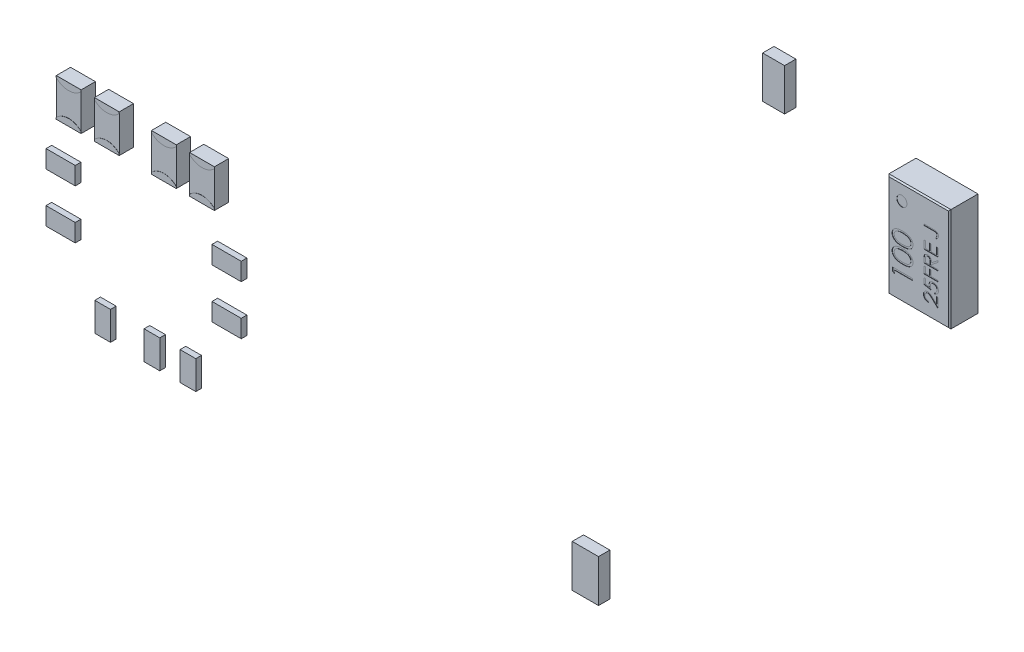
from build123d import *

# Parameters (mm, degrees)
SZKIC1_W                      = 4.373721056
SZKIC1_H                      = 7.300749762
DODANIE_WYCI_GNI_CIE1_DEPTH   = 2
SFAZOWANIE1_SIZE              = 0.09
SZKIC2_R                      = 0.357953931
WYTNIJ_WYCI_GNI_CIE1_DEPTH    = 0.02
SZKIC3_W                      = 2.452582434
SZKIC3_H                      = 1.034404964
DODANIE_WYCI_GNI_CIE2_DEPTH   = 0.1
SZKIC4_W                      = 1.85738294
SZKIC4_H                      = 2.99399041
DODANIE_WYCI_GNI_CIE3_DEPTH   = 0.8
SZKIC4_W_2                    = 1.547624374
SZKIC4_H_2                    = 2.960672714
DODANIE_WYCI_GNI_CIE3_2_DEPTH = 0.8
SZKIC5_W                      = 1.752306705
SZKIC5_H                      = 2.673622601
DODANIE_WYCI_GNI_CIE4_DEPTH   = 1
DODANIE_WYCI_GNI_CIE4_2_DEPTH = 1
DODANIE_WYCI_GNI_CIE4_3_DEPTH = 1
DODANIE_WYCI_GNI_CIE4_4_DEPTH = 1
DODANIE_WYCI_GNI_CIE5_DEPTH   = 0.01
DODANIE_WYCI_GNI_CIE5_2_DEPTH = 0.01
DODANIE_WYCI_GNI_CIE5_3_DEPTH = 0.01
DODANIE_WYCI_GNI_CIE5_4_DEPTH = 0.01
DODANIE_WYCI_GNI_CIE5_5_DEPTH = 0.01
DODANIE_WYCI_GNI_CIE5_6_DEPTH = 0.01
DODANIE_WYCI_GNI_CIE5_7_DEPTH = 0.01
DODANIE_WYCI_GNI_CIE5_8_DEPTH = 0.01
SZKIC7_W                      = 2.063385055
SZKIC7_H                      = 1.252139649
DODANIE_WYCI_GNI_CIE6_DEPTH   = 0.4
SZKIC7_W_2                    = 1.109303583
SZKIC7_H_2                    = 2.016915605
DODANIE_WYCI_GNI_CIE6_2_DEPTH = 0.4
SZKIC7_W_3                    = 2.063385056
DODANIE_WYCI_GNI_CIE6_3_DEPTH = 0.4
DODANIE_WYCI_GNI_CIE6_4_DEPTH = 0.4
DODANIE_WYCI_GNI_CIE6_5_DEPTH = 0.4
DODANIE_WYCI_GNI_CIE6_6_DEPTH = 0.4
DODANIE_WYCI_GNI_CIE6_7_DEPTH = 0.4


with BuildPart() as part:
    # Szkic1 → Dodanie-wyciągnięcie1 (new body)
    with BuildSketch(Plane.XY):
        with Locations((30.503224467, 15.085500347)):
            Rectangle(SZKIC1_W, SZKIC1_H)
    extrude(amount=DODANIE_WYCI_GNI_CIE1_DEPTH)

    # Sfazowanie1
    sfazowanie1_edges = [part.edges().sort_by_distance(p)[0] for p in [
        (30.503224467, 18.735875228, 2),
        (28.316363939, 15.085500347, 2),
        (30.503224467, 11.435125466, 2),
        (32.690084995, 15.085500347, 2),
    ]]
    chamfer(sfazowanie1_edges, length=SFAZOWANIE1_SIZE)

    # Szkic2 → Wytnij-wyciągnięcie1 (cut)
    with BuildSketch(Plane.XY.offset(2)):
        with Locations((29.31812513, 17.607576916)):
            Circle(SZKIC2_R)
        Polygon((28.664949594, 12.997179442), (28.664949594, 13.256033609), (30.064949594, 13.256033609), (30.064949594, 13.130392583), (28.808539337, 13.130392583), (28.808539337, 12.915007968), align=None)
        with BuildLine():
            add(Edge.make_bspline(
                [(29.365510491, 13.776546429), (29.343071536, 13.776677637), (29.299483542, 13.776932509), (29.235969686, 13.779767877), (29.17638557, 13.784478014), (29.120728344, 13.790932963), (29.068983637, 13.798788154), (29.021289737, 13.809274352), (28.977425884, 13.821199463), (28.937249101, 13.835020476), (28.900217893, 13.850615473), (28.865648259, 13.867589593), (28.833589905, 13.886614038), (28.803540441, 13.906610068), (28.775958808, 13.928356125), (28.750527213, 13.951385933), (28.727460125, 13.97616009), (28.706741747, 14.002438311), (28.688574754, 14.030042496), (28.672474095, 14.058218325), (28.659212068, 14.087469238), (28.648363364, 14.117410163), (28.639507318, 14.148104204), (28.633424121, 14.179543526), (28.629603389, 14.211801006), (28.629237645, 14.233573452), (28.629052158, 14.24461534)],
                knots=[0, 0, 0, 0, 1.646148282, 3.197666765, 4.66315463, 6.030252048, 7.307778049, 8.501004361, 9.610818041, 10.641065266, 11.615491391, 12.557119604, 13.464013759, 14.348536654, 15.203310953, 16.038349431, 16.863300206, 17.683791446, 18.490318933, 19.285717724, 20.06220424, 20.843281102, 21.620494212, 22.403315558, 23.190242141, 24, 24, 24, 24], degree=3))
            add(Edge.make_bspline(
                [(28.629052158, 14.24461534), (28.629206658, 14.255754931), (28.629514058, 14.277918796), (28.633840906, 14.310568856), (28.639425693, 14.342650207), (28.648382772, 14.373676112), (28.659101079, 14.404233211), (28.673243715, 14.433561612), (28.688624929, 14.46269676), (28.707388717, 14.490315086), (28.72812579, 14.517241775), (28.75166767, 14.542482734), (28.777362832, 14.566683191), (28.805784354, 14.588929102), (28.836496448, 14.610173898), (28.869756572, 14.629611104), (28.905491017, 14.647644978), (28.943534121, 14.66461451), (28.984902077, 14.679453918), (29.02933686, 14.692647337), (29.07724085, 14.703461577), (29.12834719, 14.712404763), (29.182909062, 14.719346378), (29.240815915, 14.724398368), (29.302103978, 14.727067905), (29.344007131, 14.727570543), (29.365510491, 14.727828481)],
                knots=[0, 0, 0, 0, 0.810910589, 1.61342667, 2.396193133, 3.181089899, 3.963115317, 4.752255436, 5.550715454, 6.36105385, 7.181178335, 8.024612154, 8.872680183, 9.750181803, 10.651284446, 11.591556747, 12.554036451, 13.566402641, 14.62422919, 15.753422176, 16.94128843, 18.199818041, 19.531985927, 20.947085226, 22.433341622, 24, 24, 24, 24], degree=3))
            add(Edge.make_bspline(
                [(29.365510491, 14.727828481), (29.386919867, 14.727564868), (29.42872854, 14.727050081), (29.489743711, 14.724455622), (29.547338434, 14.719222981), (29.601574114, 14.712773093), (29.652475896, 14.70372995), (29.700010612, 14.69283371), (29.744346558, 14.680419065), (29.785166072, 14.665351912), (29.82314316, 14.64877736), (29.858614851, 14.630762837), (29.891866192, 14.611435319), (29.922659295, 14.590509146), (29.950966737, 14.567897312), (29.976750029, 14.543713818), (30.000441645, 14.518252475), (30.021407179, 14.491168809), (30.040313825, 14.463293235), (30.056253215, 14.434155126), (30.070063761, 14.404500205), (30.081355157, 14.374032397), (30.090111766, 14.34279874), (30.096131458, 14.3106954), (30.100362839, 14.277914189), (30.100685074, 14.25575339), (30.10084703, 14.24461534)],
                knots=[0, 0, 0, 0, 1.561645053, 3.049612875, 4.452756685, 5.778837748, 7.032101753, 8.221335837, 9.334924186, 10.387562255, 11.392109817, 12.355697819, 13.287721948, 14.19548756, 15.068665045, 15.927346723, 16.771751757, 17.602390507, 18.423119567, 19.225778204, 20.022010933, 20.807278863, 21.593079439, 22.384715467, 23.188155646, 24, 24, 24, 24], degree=3))
            add(Edge.make_bspline(
                [(30.10084703, 14.24461534), (30.100660487, 14.233573694), (30.100292663, 14.211801724), (30.09648717, 14.179540754), (30.090368969, 14.148227777), (30.081802328, 14.117708274), (30.07131639, 14.087825673), (30.057654929, 14.05898714), (30.041921255, 14.030872135), (30.024003262, 14.003555253), (30.003473919, 13.97755138), (29.980770755, 13.95270816), (29.955311583, 13.929672673), (29.927497232, 13.908115174), (29.89740306, 13.887907751), (29.865008872, 13.869047702), (29.830259353, 13.851717622), (29.792935484, 13.835856186), (29.752473545, 13.821793254), (29.708497878, 13.809419246), (29.660561823, 13.799536507), (29.608908759, 13.791159357), (29.553433732, 13.784446637), (29.494116672, 13.779769833), (29.431070217, 13.776934661), (29.387762517, 13.776678202), (29.365510491, 13.776546429)],
                knots=[0, 0, 0, 0, 0.810927267, 1.598990287, 2.382942141, 3.152806972, 3.926217614, 4.706701772, 5.493896336, 6.292070767, 7.104102563, 7.925577746, 8.761822141, 9.623241997, 10.509042271, 11.423174113, 12.375371989, 13.360203808, 14.400680605, 15.520553799, 16.714061498, 17.994519714, 19.364400916, 20.818312473, 22.365209998, 24, 24, 24, 24], degree=3))
        make_face()
        with BuildLine():
            add(Edge.make_bspline(
                [(29.364949594, 13.902187455), (29.383648998, 13.902236282), (29.419940871, 13.902331044), (29.472586001, 13.904735007), (29.521770614, 13.908081079), (29.567475515, 13.912290629), (29.609540965, 13.918595029), (29.648141847, 13.925747757), (29.683206711, 13.934327017), (29.715041982, 13.944527874), (29.744098461, 13.956147643), (29.771150605, 13.968812114), (29.796519034, 13.982537915), (29.820142198, 13.997606397), (29.841731332, 14.014315472), (29.861833671, 14.031890508), (29.879750072, 14.051123248), (29.901241577, 14.077723562), (29.92344887, 14.11284271), (29.942787415, 14.157090724), (29.95494037, 14.202558146), (29.956485876, 14.233418641), (29.957257286, 14.24882207)],
                knots=[0, 0, 0, 0, 1.459098681, 2.831824031, 4.11146945, 5.306290378, 6.412266529, 7.42953815, 8.369053297, 9.227277979, 10.03601793, 10.809473603, 11.557037441, 12.285528272, 12.993193355, 13.685654407, 14.36688038, 15.041354379, 16.352855396, 17.594313975, 18.799247529, 20, 20, 20, 20], degree=3))
            add(Edge.make_bspline(
                [(29.957257286, 14.24882207), (29.956581824, 14.264314664), (29.955233297, 14.295244897), (29.943463884, 14.340670553), (29.924330555, 14.384405148), (29.902471181, 14.418920026), (29.881520504, 14.445105466), (29.863678632, 14.463873824), (29.843695176, 14.481098209), (29.822135766, 14.497435159), (29.798586687, 14.512418756), (29.773161681, 14.526044021), (29.745790003, 14.538477357), (29.726682108, 14.545560976), (29.716912735, 14.549182647)],
                knots=[0, 0, 0, 0, 1.353621445, 2.702441307, 4.075953605, 5.516772412, 6.261413105, 7.007624062, 7.778524365, 8.566925914, 9.372323995, 10.217594641, 11.088702136, 12, 12, 12, 12], degree=3))
            add(Edge.make_bspline(
                [(29.716912735, 14.549182647), (29.704420839, 14.553403354), (29.679056933, 14.5619732), (29.639711472, 14.57301791), (29.598430367, 14.581716069), (29.55546032, 14.589541416), (29.51048444, 14.594882638), (29.463641886, 14.599181763), (29.414897341, 14.601714038), (29.381779345, 14.602027939), (29.364949594, 14.602187455)],
                knots=[0, 0, 0, 0, 0.884706709, 1.796334032, 2.740027952, 3.714592787, 4.726048262, 5.777819803, 6.87074269, 8, 8, 8, 8], degree=3))
            add(Edge.make_bspline(
                [(29.364949594, 14.602187455), (29.348122565, 14.601967379), (29.315205299, 14.601536864), (29.266998027, 14.599891269), (29.221210922, 14.595641839), (29.177646733, 14.590922192), (29.136546611, 14.583963304), (29.097566492, 14.576460178), (29.061189271, 14.566379704), (29.026845478, 14.555611756), (28.99492508, 14.54328773), (28.965280036, 14.529720979), (28.937764498, 14.515233877), (28.912463481, 14.499491383), (28.889230228, 14.482712776), (28.868599334, 14.464296467), (28.84956722, 14.44541203), (28.828230815, 14.418554379), (28.806304137, 14.383678902), (28.786674781, 14.339982679), (28.775057599, 14.294758972), (28.773446553, 14.26412333), (28.772641901, 14.24882207)],
                knots=[0, 0, 0, 0, 1.313483664, 2.569454835, 3.763100662, 4.901599063, 5.988328865, 7.015709358, 7.99797933, 8.932480776, 9.824041341, 10.666387587, 11.475829342, 12.24921787, 12.990555181, 13.709176526, 14.405678811, 15.080244297, 16.38186033, 17.610124501, 18.806354173, 20, 20, 20, 20], degree=3))
            add(Edge.make_bspline(
                [(28.772641901, 14.24882207), (28.773448555, 14.233335481), (28.775063333, 14.202334091), (28.786621056, 14.156627436), (28.806246705, 14.112636019), (28.828188571, 14.077645536), (28.849485414, 14.05111416), (28.86761148, 14.032286874), (28.887233683, 14.014468097), (28.909014337, 13.998191701), (28.932554265, 13.983212572), (28.957594636, 13.968956317), (28.984697327, 13.956461203), (29.013731021, 13.94480413), (29.045568044, 13.934586258), (29.080759784, 13.926105025), (29.119452848, 13.918383866), (29.161825653, 13.912823373), (29.207540308, 13.907926989), (29.256850702, 13.904771741), (29.309676611, 13.902320032), (29.346156252, 13.902232532), (29.364949594, 13.902187455)],
                knots=[0, 0, 0, 0, 1.207546505, 2.417292871, 3.651582144, 4.952510111, 5.626719005, 6.30238548, 6.989136872, 7.692112372, 8.420316868, 9.164734959, 9.937886623, 10.746308695, 11.604196049, 12.543341915, 13.568754172, 14.680483261, 15.875568977, 17.154711427, 18.534182925, 20, 20, 20, 20], degree=3))
        make_face(mode=Mode.SUBTRACT)
        with BuildLine():
            add(Edge.make_bspline(
                [(29.365510491, 14.853469506), (29.343071536, 14.853600714), (29.299483542, 14.853855586), (29.235969686, 14.856690954), (29.17638557, 14.861401091), (29.120728344, 14.86785604), (29.068983637, 14.875711231), (29.021289737, 14.886197429), (28.977425884, 14.89812254), (28.937249101, 14.911943552), (28.900217893, 14.92753855), (28.865648259, 14.94451267), (28.833589905, 14.963537115), (28.803540441, 14.983533145), (28.775958808, 15.005279202), (28.750527213, 15.02830901), (28.727460125, 15.053083167), (28.706741747, 15.079361388), (28.688574754, 15.106965573), (28.672474095, 15.135141402), (28.659212068, 15.164392315), (28.648363364, 15.19433324), (28.639507318, 15.225027281), (28.633424121, 15.256466603), (28.629603389, 15.288724083), (28.629237645, 15.310496529), (28.629052158, 15.321538417)],
                knots=[0, 0, 0, 0, 1.646148282, 3.197666765, 4.66315463, 6.030252048, 7.307778049, 8.501004361, 9.610818041, 10.641065266, 11.615491391, 12.557119604, 13.464013759, 14.348536654, 15.203310953, 16.038349431, 16.863300206, 17.683791446, 18.490318933, 19.285717724, 20.06220424, 20.843281102, 21.620494212, 22.403315558, 23.190242141, 24, 24, 24, 24], degree=3))
            add(Edge.make_bspline(
                [(28.629052158, 15.321538417), (28.629206658, 15.332678008), (28.629514058, 15.354841873), (28.633840906, 15.387491933), (28.639425693, 15.419573284), (28.648382772, 15.450599189), (28.659101079, 15.481156288), (28.673243715, 15.510484689), (28.688624929, 15.539619837), (28.707388717, 15.567238163), (28.72812579, 15.594164852), (28.75166767, 15.619405811), (28.777362832, 15.643606268), (28.805784354, 15.665852179), (28.836496448, 15.687096975), (28.869756572, 15.706534181), (28.905491017, 15.724568055), (28.943534121, 15.741537587), (28.984902077, 15.756376995), (29.02933686, 15.769570414), (29.07724085, 15.780384654), (29.12834719, 15.78932784), (29.182909062, 15.796269455), (29.240815915, 15.801321445), (29.302103978, 15.803990982), (29.344007131, 15.80449362), (29.365510491, 15.804751558)],
                knots=[0, 0, 0, 0, 0.810910589, 1.61342667, 2.396193133, 3.181089899, 3.963115317, 4.752255436, 5.550715454, 6.36105385, 7.181178335, 8.024612154, 8.872680183, 9.750181803, 10.651284446, 11.591556747, 12.554036451, 13.566402641, 14.62422919, 15.753422176, 16.94128843, 18.199818041, 19.531985927, 20.947085226, 22.433341622, 24, 24, 24, 24], degree=3))
            add(Edge.make_bspline(
                [(29.365510491, 15.804751558), (29.386919867, 15.804487945), (29.42872854, 15.803973157), (29.489743711, 15.801378699), (29.547338434, 15.796146058), (29.601574114, 15.78969617), (29.652475896, 15.780653026), (29.700010612, 15.769756787), (29.744346558, 15.757342142), (29.785166072, 15.742274989), (29.82314316, 15.725700437), (29.858614851, 15.707685914), (29.891866192, 15.688358396), (29.922659295, 15.667432223), (29.950966737, 15.644820389), (29.976750029, 15.620636895), (30.000441645, 15.595175552), (30.021407179, 15.568091886), (30.040313825, 15.540216312), (30.056253215, 15.511078203), (30.070063761, 15.481423282), (30.081355157, 15.450955474), (30.090111766, 15.419721817), (30.096131458, 15.387618477), (30.100362839, 15.354837266), (30.100685074, 15.332676466), (30.10084703, 15.321538417)],
                knots=[0, 0, 0, 0, 1.561645053, 3.049612875, 4.452756685, 5.778837748, 7.032101753, 8.221335837, 9.334924186, 10.387562255, 11.392109817, 12.355697819, 13.287721948, 14.19548756, 15.068665045, 15.927346723, 16.771751757, 17.602390507, 18.423119567, 19.225778204, 20.022010933, 20.807278863, 21.593079439, 22.384715467, 23.188155646, 24, 24, 24, 24], degree=3))
            add(Edge.make_bspline(
                [(30.10084703, 15.321538417), (30.100660487, 15.310496771), (30.100292663, 15.288724801), (30.09648717, 15.256463831), (30.090368969, 15.225150854), (30.081802328, 15.194631351), (30.07131639, 15.16474875), (30.057654929, 15.135910217), (30.041921255, 15.107795212), (30.024003262, 15.08047833), (30.003473919, 15.054474457), (29.980770755, 15.029631237), (29.955311583, 15.00659575), (29.927497232, 14.985038251), (29.89740306, 14.964830827), (29.865008872, 14.945970779), (29.830259353, 14.928640699), (29.792935484, 14.912779263), (29.752473545, 14.898716331), (29.708497878, 14.886342323), (29.660561823, 14.876459584), (29.608908759, 14.868082434), (29.553433732, 14.861369714), (29.494116672, 14.85669291), (29.431070217, 14.853857738), (29.387762517, 14.853601278), (29.365510491, 14.853469506)],
                knots=[0, 0, 0, 0, 0.810927267, 1.598990287, 2.382942141, 3.152806972, 3.926217614, 4.706701772, 5.493896336, 6.292070767, 7.104102563, 7.925577746, 8.761822141, 9.623241997, 10.509042271, 11.423174113, 12.375371989, 13.360203808, 14.400680605, 15.520553799, 16.714061498, 17.994519714, 19.364400916, 20.818312473, 22.365209998, 24, 24, 24, 24], degree=3))
        make_face()
        with BuildLine():
            add(Edge.make_bspline(
                [(29.364949594, 14.979110532), (29.383648998, 14.979159358), (29.419940871, 14.979254121), (29.472586001, 14.981658084), (29.521770614, 14.985004155), (29.567475515, 14.989213706), (29.609540965, 14.995518106), (29.648141847, 15.002670833), (29.683206711, 15.011250094), (29.715041982, 15.021450951), (29.744098461, 15.03307072), (29.771150605, 15.045735191), (29.796519034, 15.059460992), (29.820142198, 15.074529473), (29.841731332, 15.091238549), (29.861833671, 15.108813584), (29.879750072, 15.128046325), (29.901241577, 15.154646639), (29.92344887, 15.189765787), (29.942787415, 15.234013801), (29.95494037, 15.279481223), (29.956485876, 15.310341718), (29.957257286, 15.325745147)],
                knots=[0, 0, 0, 0, 1.459098681, 2.831824031, 4.11146945, 5.306290378, 6.412266529, 7.42953815, 8.369053297, 9.227277979, 10.03601793, 10.809473603, 11.557037441, 12.285528272, 12.993193355, 13.685654407, 14.36688038, 15.041354379, 16.352855396, 17.594313975, 18.799247529, 20, 20, 20, 20], degree=3))
            add(Edge.make_bspline(
                [(29.957257286, 15.325745147), (29.956581824, 15.341237741), (29.955233297, 15.372167974), (29.943463884, 15.41759363), (29.924330555, 15.461328225), (29.902471181, 15.495843103), (29.881520504, 15.522028543), (29.863678632, 15.540796901), (29.843695176, 15.558021286), (29.822135766, 15.574358236), (29.798586687, 15.589341833), (29.773161681, 15.602967098), (29.745790003, 15.615400434), (29.726682108, 15.622484053), (29.716912735, 15.626105724)],
                knots=[0, 0, 0, 0, 1.353621445, 2.702441307, 4.075953605, 5.516772412, 6.261413105, 7.007624062, 7.778524365, 8.566925914, 9.372323995, 10.217594641, 11.088702136, 12, 12, 12, 12], degree=3))
            add(Edge.make_bspline(
                [(29.716912735, 15.626105724), (29.704420839, 15.630326431), (29.679056933, 15.638896277), (29.639711472, 15.649940987), (29.598430367, 15.658639146), (29.55546032, 15.666464493), (29.51048444, 15.671805715), (29.463641886, 15.67610484), (29.414897341, 15.678637115), (29.381779345, 15.678951015), (29.364949594, 15.679110532)],
                knots=[0, 0, 0, 0, 0.884706709, 1.796334032, 2.740027952, 3.714592787, 4.726048262, 5.777819803, 6.87074269, 8, 8, 8, 8], degree=3))
            add(Edge.make_bspline(
                [(29.364949594, 15.679110532), (29.348122565, 15.678890456), (29.315205299, 15.678459941), (29.266998027, 15.676814346), (29.221210922, 15.672564916), (29.177646733, 15.667845269), (29.136546611, 15.660886381), (29.097566492, 15.653383255), (29.061189271, 15.643302781), (29.026845478, 15.632534833), (28.99492508, 15.620210807), (28.965280036, 15.606644056), (28.937764498, 15.592156954), (28.912463481, 15.57641446), (28.889230228, 15.559635852), (28.868599334, 15.541219544), (28.84956722, 15.522335106), (28.828230815, 15.495477456), (28.806304137, 15.460601979), (28.786674781, 15.416905756), (28.775057599, 15.371682049), (28.773446553, 15.341046407), (28.772641901, 15.325745147)],
                knots=[0, 0, 0, 0, 1.313483664, 2.569454835, 3.763100662, 4.901599063, 5.988328865, 7.015709358, 7.99797933, 8.932480776, 9.824041341, 10.666387587, 11.475829342, 12.24921787, 12.990555181, 13.709176526, 14.405678811, 15.080244297, 16.38186033, 17.610124501, 18.806354173, 20, 20, 20, 20], degree=3))
            add(Edge.make_bspline(
                [(28.772641901, 15.325745147), (28.773448555, 15.310258558), (28.775063333, 15.279257168), (28.786621056, 15.233550513), (28.806246705, 15.189559096), (28.828188571, 15.154568613), (28.849485414, 15.128037237), (28.86761148, 15.109209951), (28.887233683, 15.091391174), (28.909014337, 15.075114778), (28.932554265, 15.060135648), (28.957594636, 15.045879394), (28.984697327, 15.03338428), (29.013731021, 15.021727207), (29.045568044, 15.011509335), (29.080759784, 15.003028102), (29.119452848, 14.995306943), (29.161825653, 14.98974645), (29.207540308, 14.984850066), (29.256850702, 14.981694818), (29.309676611, 14.979243108), (29.346156252, 14.979155609), (29.364949594, 14.979110532)],
                knots=[0, 0, 0, 0, 1.207546505, 2.417292871, 3.651582144, 4.952510111, 5.626719005, 6.30238548, 6.989136872, 7.692112372, 8.420316868, 9.164734959, 9.937886623, 10.746308695, 11.604196049, 12.543341915, 13.568754172, 14.680483261, 15.875568977, 17.154711427, 18.534182925, 20, 20, 20, 20], degree=3))
        make_face(mode=Mode.SUBTRACT)
        with BuildLine():
            Line((31.179149727, 12.445550109), (31.179149727, 12.355806519))
            add(Edge.make_bspline(
                [(31.179149727, 12.355806519), (31.167243759, 12.35639142), (31.143860754, 12.35754015), (31.10976821, 12.362919661), (31.077181124, 12.370617055), (31.046361149, 12.381500327), (31.017035775, 12.395016407), (30.989321485, 12.411224986), (30.963324003, 12.430423229), (30.939284333, 12.452196581), (30.917230742, 12.475844764), (30.898186387, 12.501360747), (30.882095623, 12.528173612), (30.86864384, 12.556202011), (30.858546741, 12.585762172), (30.851054844, 12.616585846), (30.846547317, 12.648808456), (30.846062807, 12.670762748), (30.845816393, 12.681928314)],
                knots=[0, 0, 0, 0, 1.10065271, 2.161652631, 3.183658789, 4.190468796, 5.17591951, 6.163126047, 7.15150782, 8.156236427, 9.156009102, 10.134482811, 11.092018607, 12.041330605, 13.001268258, 13.972401359, 14.968799086, 16, 16, 16, 16], degree=3))
            add(Edge.make_bspline(
                [(30.845816393, 12.681928314), (30.846071012, 12.69289425), (30.846571329, 12.714441922), (30.850932521, 12.745877295), (30.857615659, 12.775874181), (30.867519017, 12.804092624), (30.879945565, 12.830822225), (30.895399605, 12.855732027), (30.913149905, 12.879424376), (30.934087254, 12.900736491), (30.956427458, 12.920314241), (30.980286608, 12.937189077), (31.004957704, 12.951721819), (31.030633463, 12.963616414), (31.057397498, 12.972633046), (31.084993212, 12.979313506), (31.113739079, 12.983132418), (31.133198655, 12.983715304), (31.143092034, 12.984011648)],
                knots=[0, 0, 0, 0, 1.111674182, 2.184400057, 3.212814286, 4.223731311, 5.211378316, 6.196328225, 7.191884489, 8.207283132, 9.220262353, 10.201199469, 11.166417575, 12.120932471, 13.06540007, 14.026332106, 14.996573967, 16, 16, 16, 16], degree=3))
            add(Edge.make_bspline(
                [(31.143092034, 12.984011648), (31.157019981, 12.983527851), (31.184631459, 12.982568747), (31.225207222, 12.97436475), (31.264519293, 12.961551037), (31.2961596, 12.946124588), (31.32165247, 12.930557973), (31.342652403, 12.916544222), (31.365257735, 12.900045511), (31.389559961, 12.881202795), (31.415240822, 12.859691578), (31.442824277, 12.836070717), (31.471800288, 12.809730196), (31.491604188, 12.791259159), (31.501866073, 12.78168793)],
                knots=[0, 0, 0, 0, 1.184416499, 2.348048165, 3.509039915, 4.696071444, 5.333504901, 6.05069495, 6.844171097, 7.714965912, 8.667477798, 9.695072654, 10.805644396, 12, 12, 12, 12], degree=3))
            Line((31.501866073, 12.78168793), (31.768893316, 12.531487609))
            Line((31.768893316, 12.531487609), (31.768893316, 12.99683216))
            Line((31.768893316, 12.99683216), (31.871457419, 12.99683216))
            Line((31.871457419, 12.99683216), (31.871457419, 12.317344981))
            Line((31.871457419, 12.317344981), (31.457595239, 12.705165494))
            add(Edge.make_bspline(
                [(31.457595239, 12.705165494), (31.44773858, 12.714607747), (31.428805956, 12.732744383), (31.40116511, 12.758396548), (31.375522384, 12.781436259), (31.351926227, 12.802012657), (31.330031494, 12.819679373), (31.310547293, 12.835357153), (31.29261745, 12.847918751), (31.271834417, 12.861551721), (31.246459469, 12.874755716), (31.215449844, 12.886102103), (31.183527772, 12.893020631), (31.161955761, 12.893850584), (31.151104855, 12.894268058)],
                knots=[0, 0, 0, 0, 1.329631726, 2.553950428, 3.673215718, 4.687767853, 5.603093632, 6.413772471, 7.123043292, 7.734684054, 8.834405432, 9.900288307, 10.943827018, 12, 12, 12, 12], degree=3))
            add(Edge.make_bspline(
                [(31.151104855, 12.894268058), (31.144281598, 12.894086417), (31.130834269, 12.893728438), (31.111118338, 12.890569096), (31.09209982, 12.885794666), (31.073720215, 12.878953164), (31.056164314, 12.869922666), (31.039410748, 12.858930272), (31.023213901, 12.846247397), (31.008027244, 12.831575606), (30.994118329, 12.815458029), (30.981797161, 12.7984311), (30.971500272, 12.780416785), (30.963059273, 12.761491035), (30.956437736, 12.741706616), (30.95184957, 12.72102526), (30.948968861, 12.699504112), (30.948579097, 12.684808828), (30.948380496, 12.677320942)],
                knots=[0, 0, 0, 0, 0.991446411, 1.95395049, 2.89581595, 3.838931463, 4.798493298, 5.75982156, 6.748411868, 7.785213223, 8.824556874, 9.840280684, 10.836137867, 11.835679398, 12.848801643, 13.863922112, 14.911575587, 16, 16, 16, 16], degree=3))
            add(Edge.make_bspline(
                [(30.948380496, 12.677320942), (30.94857673, 12.669498742), (30.9489621, 12.654137231), (30.95188109, 12.631631005), (30.956306281, 12.610012794), (30.963334449, 12.589605159), (30.971638579, 12.569966188), (30.982188082, 12.551515141), (30.994446838, 12.533945674), (31.008661365, 12.51754677), (31.024632415, 12.502569352), (31.042233614, 12.489224689), (31.061338248, 12.477641523), (31.081867907, 12.467521203), (31.104026992, 12.459306245), (31.127731806, 12.453027932), (31.152880841, 12.448060337), (31.170247998, 12.446400749), (31.179149727, 12.445550109)],
                knots=[0, 0, 0, 0, 1.030878251, 2.024474673, 2.987898669, 3.934362936, 4.864849709, 5.795128259, 6.730474222, 7.685293701, 8.650606017, 9.611896181, 10.591709709, 11.591680886, 12.625074257, 13.701333388, 14.821793024, 16, 16, 16, 16], degree=3))
        make_face()
        with BuildLine():
            Line((30.871457419, 13.714780878), (30.974021521, 13.714780878))
            Line((30.974021521, 13.714780878), (30.974021521, 13.374636648))
            Line((30.974021521, 13.374636648), (31.237042355, 13.32075043))
            add(Edge.make_bspline(
                [(31.237042355, 13.32075043), (31.23411942, 13.331337822), (31.228456696, 13.351849221), (31.222169333, 13.382123467), (31.218379206, 13.410864097), (31.217861689, 13.429514202), (31.217611265, 13.438538891)],
                knots=[0, 0, 0, 0, 1.100273476, 2.13160584, 3.095893838, 4, 4, 4, 4], degree=3))
            add(Edge.make_bspline(
                [(31.217611265, 13.438538891), (31.217844979, 13.449707724), (31.218304519, 13.471668439), (31.222979137, 13.503749669), (31.229749941, 13.534528908), (31.240181645, 13.563551703), (31.252920617, 13.591277224), (31.268965631, 13.617229318), (31.287698145, 13.641772225), (31.309021682, 13.664736316), (31.332733288, 13.685471459), (31.358333438, 13.703489614), (31.385263493, 13.719216121), (31.41415464, 13.731481385), (31.444461982, 13.741491038), (31.476535367, 13.748091427), (31.510090055, 13.752500201), (31.533034485, 13.752991756), (31.544734662, 13.753242417)],
                knots=[0, 0, 0, 0, 1.052805225, 2.070078116, 3.052532748, 4.020689046, 4.973125432, 5.925915817, 6.89216474, 7.881560752, 8.877013184, 9.857446635, 10.830895175, 11.812622661, 12.812548702, 13.836681939, 14.896847428, 16, 16, 16, 16], degree=3))
            add(Edge.make_bspline(
                [(31.544734662, 13.753242417), (31.552883817, 13.753052224), (31.569071998, 13.752674409), (31.593113945, 13.750757322), (31.616643406, 13.747052067), (31.639617244, 13.742137748), (31.662056975, 13.735577375), (31.684088239, 13.727903825), (31.705469794, 13.718366112), (31.726296076, 13.70779249), (31.746328733, 13.696084198), (31.765087446, 13.682918483), (31.783000294, 13.669238547), (31.799535292, 13.654290691), (31.814756577, 13.638244864), (31.828739398, 13.621190347), (31.841734706, 13.603281827), (31.853211159, 13.584237247), (31.863772051, 13.564482313), (31.872435906, 13.543731377), (31.880181775, 13.522456896), (31.886355924, 13.500352645), (31.891193797, 13.477468698), (31.894479683, 13.453767334), (31.896872951, 13.429372857), (31.897022767, 13.412837139), (31.897098444, 13.404484404)],
                knots=[0, 0, 0, 0, 1.056393913, 2.098511576, 3.122979385, 4.141471433, 5.141222888, 6.151259816, 7.162667642, 8.172852865, 9.177685681, 10.166741883, 11.141342384, 12.097242845, 13.052202613, 14.005160326, 14.953864445, 15.917140761, 16.884916217, 17.854238259, 18.828761908, 19.81781811, 20.826036654, 21.857789401, 22.917898972, 24, 24, 24, 24], degree=3))
            add(Edge.make_bspline(
                [(31.897098444, 13.404484404), (31.896900531, 13.394520606), (31.896511161, 13.374918012), (31.892456303, 13.346194228), (31.886610409, 13.31857471), (31.877949399, 13.29217783), (31.866608424, 13.267113679), (31.853133629, 13.243023344), (31.837092093, 13.220205413), (31.818630541, 13.198815887), (31.798345185, 13.179154171), (31.776542401, 13.161324782), (31.753194423, 13.145649457), (31.72837717, 13.132071335), (31.702134662, 13.120504012), (31.674386041, 13.111413039), (31.645271533, 13.104076634), (31.625227703, 13.100972763), (31.615047162, 13.099396263)],
                knots=[0, 0, 0, 0, 1.046872515, 2.059598001, 3.044168548, 4.012104806, 4.973680974, 5.932408326, 6.910122221, 7.900780896, 8.89867654, 9.876692837, 10.858029398, 11.85084981, 12.847361615, 13.868568023, 14.917415949, 16, 16, 16, 16], degree=3))
            Line((31.615047162, 13.099396263), (31.615047162, 13.189139853))
            add(Edge.make_bspline(
                [(31.615047162, 13.189139853), (31.624584285, 13.191346631), (31.642915163, 13.19558818), (31.668653762, 13.204922492), (31.691598099, 13.216224482), (31.711888459, 13.229977036), (31.729896253, 13.245918006), (31.745773685, 13.26444856), (31.760115341, 13.28510544), (31.772090342, 13.308071834), (31.782177665, 13.332348423), (31.789376311, 13.357612165), (31.793733806, 13.383499466), (31.794266492, 13.400928786), (31.794534342, 13.409692737)],
                knots=[0, 0, 0, 0, 1.13623081, 2.183898708, 3.172478118, 4.09966615, 5.022692284, 5.957376522, 6.927682873, 7.937366477, 8.960015386, 9.976409503, 10.982481913, 12, 12, 12, 12], degree=3))
            add(Edge.make_bspline(
                [(31.794534342, 13.409692737), (31.794297872, 13.418251567), (31.79383226, 13.435103972), (31.790306401, 13.45991764), (31.784733535, 13.483804284), (31.77692627, 13.506806306), (31.766597717, 13.528810678), (31.753909683, 13.549786288), (31.739178726, 13.570031953), (31.722341779, 13.589014837), (31.703776916, 13.60639662), (31.683926779, 13.621755751), (31.662750394, 13.634549092), (31.640615246, 13.645330283), (31.617278505, 13.653516935), (31.5928496, 13.659357217), (31.567268177, 13.662786662), (31.549819803, 13.663258428), (31.540928573, 13.663498827)],
                knots=[0, 0, 0, 0, 1.027268864, 2.022700798, 3.002744649, 3.968653148, 4.933396556, 5.915045722, 6.907600446, 7.935526002, 8.956456544, 9.95700807, 10.942805781, 11.92166854, 12.907987664, 13.905483474, 14.932689774, 16, 16, 16, 16], degree=3))
            add(Edge.make_bspline(
                [(31.540928573, 13.663498827), (31.532905981, 13.663316406), (31.517269121, 13.66296085), (31.494311792, 13.65988282), (31.472554997, 13.65474102), (31.451904068, 13.647420141), (31.432425032, 13.63828345), (31.414160815, 13.626812057), (31.396939686, 13.613494425), (31.381204816, 13.597946391), (31.366659394, 13.581033348), (31.354304767, 13.562320884), (31.343798163, 13.542308551), (31.335189857, 13.520959264), (31.328332683, 13.498246725), (31.323593597, 13.474158702), (31.320757799, 13.448689703), (31.320373108, 13.431268091), (31.320175368, 13.42231293)],
                knots=[0, 0, 0, 0, 1.045723156, 2.038222538, 3.013889863, 3.95567481, 4.890389958, 5.81331128, 6.76251276, 7.723027653, 8.692928204, 9.666105983, 10.639751036, 11.635719707, 12.66315958, 13.728667616, 14.832476222, 16, 16, 16, 16], degree=3))
            add(Edge.make_bspline(
                [(31.320175368, 13.42231293), (31.320341251, 13.414561807), (31.320683757, 13.398557706), (31.323205614, 13.374008327), (31.327273984, 13.348210691), (31.332870054, 13.321263693), (31.340193219, 13.293086405), (31.348968791, 13.26373829), (31.35946079, 13.233157643), (31.36738428, 13.212552578), (31.371457419, 13.201960366)],
                knots=[0, 0, 0, 0, 0.817624296, 1.688186739, 2.600797293, 3.572016777, 4.590301741, 5.671205678, 6.80286297, 8, 8, 8, 8], degree=3))
            Line((31.371457419, 13.201960366), (30.871457419, 13.304524468))
            Line((30.871457419, 13.304524468), (30.871457419, 13.714780878))
        make_face()
        Polygon((30.871457419, 13.945550109), (30.871457419, 14.432729596), (30.974021521, 14.432729596), (30.974021521, 14.035293699), (31.281713829, 14.035293699), (31.281713829, 14.432729596), (31.384277932, 14.432729596), (31.384277932, 14.035293699), (31.871457419, 14.035293699), (31.871457419, 13.945550109), align=None)
        with BuildLine():
            Line((30.871457419, 14.612216776), (30.871457419, 14.812336968))
            add(Edge.make_bspline(
                [(30.871457419, 14.812336968), (30.871501872, 14.825691576), (30.871587227, 14.851333903), (30.872063159, 14.888069123), (30.873427261, 14.921448294), (30.874601142, 14.951453962), (30.876741696, 14.978085578), (30.878787596, 15.001424804), (30.881465784, 15.021364146), (30.883953048, 15.033434389), (30.885079214, 15.038899468)],
                knots=[0, 0, 0, 0, 1.410062039, 2.707475311, 3.878576406, 4.937260626, 5.877586885, 6.699081471, 7.410979367, 8, 8, 8, 8], degree=3))
            add(Edge.make_bspline(
                [(30.885079214, 15.038899468), (30.886886866, 15.046215641), (30.890463608, 15.060691912), (30.898023423, 15.081534871), (30.906772148, 15.101395802), (30.917046547, 15.120194004), (30.928928583, 15.137828679), (30.94219198, 15.15450649), (30.956809948, 15.1701733), (30.972914263, 15.184624645), (30.9901618, 15.197751539), (31.008505222, 15.209265848), (31.027868683, 15.218995227), (31.048282343, 15.226630292), (31.069520702, 15.233036951), (31.09180053, 15.237341437), (31.115047449, 15.24002271), (31.130864972, 15.240287594), (31.138885303, 15.240421904)],
                knots=[0, 0, 0, 0, 1.02737844, 2.032840108, 3.019645024, 3.985760442, 4.950801802, 5.916702504, 6.889791722, 7.870143693, 8.864820395, 9.842884691, 10.820524757, 11.815201459, 12.812418953, 13.84314332, 14.906358105, 16, 16, 16, 16], degree=3))
            add(Edge.make_bspline(
                [(31.138885303, 15.240421904), (31.152209619, 15.24000219), (31.17820881, 15.23918322), (31.21594049, 15.231547476), (31.251137437, 15.219039899), (31.283755334, 15.201804674), (31.313158375, 15.179856252), (31.33898422, 15.15347774), (31.360595623, 15.122654423), (31.375582139, 15.093960332), (31.385180113, 15.068613418), (31.391933358, 15.047746757), (31.397151063, 15.024984764), (31.401825386, 15.000545525), (31.405354442, 14.974327338), (31.407939183, 14.946393041), (31.409554625, 14.916722712), (31.409795198, 14.896340121), (31.409918957, 14.885854596)],
                knots=[0, 0, 0, 0, 1.260483769, 2.459530307, 3.627416485, 4.787058657, 5.939039949, 7.08810263, 8.267026773, 9.491475466, 10.141966685, 10.831826277, 11.566392101, 12.351337768, 13.187381173, 14.07005841, 15.007169909, 16, 16, 16, 16], degree=3))
            Line((31.409918957, 14.885854596), (31.871457419, 15.253242417))
            Line((31.871457419, 15.253242417), (31.871457419, 15.142264853))
            Line((31.871457419, 15.142264853), (31.409918957, 14.774877032))
            Line((31.409918957, 14.774877032), (31.409918957, 14.701960366))
            Line((31.409918957, 14.701960366), (31.871457419, 14.701960366))
            Line((31.871457419, 14.701960366), (31.871457419, 14.612216776))
            Line((31.871457419, 14.612216776), (30.871457419, 14.612216776))
        make_face()
        with BuildLine():
            Line((30.974021521, 14.701960366), (31.307354855, 14.701960366))
            Line((31.307354855, 14.701960366), (31.308757098, 14.885053314))
            add(Edge.make_bspline(
                [(31.308757098, 14.885053314), (31.308760882, 14.893601898), (31.308768217, 14.910171488), (31.307627108, 14.934143091), (31.306329119, 14.956463174), (31.304343253, 14.977046075), (31.301785486, 14.995901945), (31.298581012, 15.013018229), (31.294863654, 15.028433078), (31.289050432, 15.046353027), (31.280242652, 15.066599993), (31.266562588, 15.088122951), (31.250124985, 15.10700762), (31.230786012, 15.122387781), (31.209860653, 15.135273849), (31.187134595, 15.143945661), (31.163345048, 15.149725056), (31.146999777, 15.150356898), (31.138684983, 15.150678314)],
                knots=[0, 0, 0, 0, 1.146477201, 2.22219935, 3.21835465, 4.145220026, 4.995151787, 5.769831222, 6.480173269, 7.120302478, 8.295254187, 9.430763426, 10.528629691, 11.636497428, 12.733230534, 13.811001502, 14.886462612, 16, 16, 16, 16], degree=3))
            add(Edge.make_bspline(
                [(31.138684983, 15.150678314), (31.13064376, 15.15033386), (31.114708992, 15.149651277), (31.091369118, 15.144109019), (31.069334111, 15.134633975), (31.048575521, 15.122169513), (31.030026577, 15.106526559), (31.013983506, 15.088536693), (31.000850043, 15.068203376), (30.992121068, 15.049366515), (30.986994926, 15.032394881), (30.983269085, 15.017729442), (30.980683213, 15.00107742), (30.978233921, 14.982514543), (30.976251152, 14.962005384), (30.974883465, 14.939489834), (30.974082487, 14.915107368), (30.974042316, 14.898208321), (30.974021521, 14.889460366)],
                knots=[0, 0, 0, 0, 1.100823979, 2.181431445, 3.263702604, 4.376021382, 5.48638238, 6.575013887, 7.666064109, 8.791843368, 9.405226397, 10.093019944, 10.863016055, 11.711746407, 12.658404307, 13.684961631, 14.801597923, 16, 16, 16, 16], degree=3))
            Line((30.974021521, 14.889460366), (30.974021521, 14.701960366))
        make_face(mode=Mode.SUBTRACT)
        Polygon((30.871457419, 15.458370622), (30.871457419, 16.022473186), (30.974021521, 16.022473186), (30.974021521, 15.548114212), (31.281713829, 15.548114212), (31.281713829, 16.022473186), (31.384277932, 16.022473186), (31.384277932, 15.548114212), (31.768893316, 15.548114212), (31.768893316, 16.022473186), (31.871457419, 16.022473186), (31.871457419, 15.458370622), align=None)
        with BuildLine():
            Line((30.871457419, 16.907088571), (30.871457419, 16.99683216))
            Line((30.871457419, 16.99683216), (31.546737868, 16.99683216))
            add(Edge.make_bspline(
                [(31.546737868, 16.99683216), (31.559225023, 16.996742114), (31.583201884, 16.996569214), (31.617737765, 16.995626918), (31.649337041, 16.99385518), (31.6779476, 16.99134955), (31.70352775, 16.98789226), (31.72622911, 16.984016715), (31.745983193, 16.979296527), (31.768164045, 16.972191885), (31.792495869, 16.960545608), (31.818748433, 16.942997408), (31.841775489, 16.921300482), (31.861442179, 16.895871121), (31.877663064, 16.867173718), (31.889001675, 16.835119356), (31.895989456, 16.800286545), (31.896721363, 16.776113248), (31.897098444, 16.763659083)],
                knots=[0, 0, 0, 0, 1.237835128, 2.376794491, 3.424301355, 4.37473024, 5.222848639, 5.982427304, 6.656694867, 7.234414123, 8.288487839, 9.318384746, 10.353268049, 11.409832686, 12.494409752, 13.606195221, 14.766703628, 16, 16, 16, 16], degree=3))
            add(Edge.make_bspline(
                [(31.897098444, 16.763659083), (31.896784244, 16.753958224), (31.896152052, 16.734439452), (31.891169012, 16.705344039), (31.883032996, 16.676446331), (31.871702294, 16.64735246), (31.856092455, 16.617739806), (31.836027103, 16.586873365), (31.810875678, 16.554774566), (31.791733762, 16.533571854), (31.781713829, 16.522473186)],
                knots=[0, 0, 0, 0, 0.848740133, 1.707721362, 2.575564419, 3.47312689, 4.435109626, 5.500187059, 6.691460208, 8, 8, 8, 8], degree=3))
            Line((31.781713829, 16.522473186), (31.704790752, 16.575357801))
            add(Edge.make_bspline(
                [(31.704790752, 16.575357801), (31.713177606, 16.587574635), (31.729032904, 16.610670489), (31.749800582, 16.644332233), (31.767010169, 16.674511644), (31.775960824, 16.694085734), (31.780111265, 16.703162289)],
                knots=[0, 0, 0, 0, 1.196678767, 2.26231444, 3.194230787, 4, 4, 4, 4], degree=3))
            add(Edge.make_bspline(
                [(31.780111265, 16.703162289), (31.782385058, 16.708658425), (31.786828991, 16.71940015), (31.791077489, 16.736062042), (31.79415386, 16.752393386), (31.794409123, 16.76331132), (31.794534342, 16.768667096)],
                knots=[0, 0, 0, 0, 1.055403208, 2.062694816, 3.049657822, 4, 4, 4, 4], degree=3))
            add(Edge.make_bspline(
                [(31.794534342, 16.768667096), (31.794236893, 16.775574201), (31.793648947, 16.789227001), (31.788618974, 16.809132278), (31.780527148, 16.828016339), (31.769208488, 16.845534041), (31.755630907, 16.861522463), (31.73943289, 16.874933807), (31.721272696, 16.885918925), (31.704091645, 16.892588703), (31.688410931, 16.896828091), (31.674001908, 16.899520507), (31.657155623, 16.901874235), (31.637852757, 16.903926164), (31.616054404, 16.905127423), (31.591824653, 16.906475221), (31.565102391, 16.906962437), (31.546470691, 16.907045243), (31.536721842, 16.907088571)],
                knots=[0, 0, 0, 0, 0.997449608, 1.971590104, 2.949026386, 3.956102178, 4.976100044, 5.969992001, 6.98334247, 8.032177332, 8.622390994, 9.330563149, 10.149808447, 11.081693721, 12.136245554, 13.305923647, 14.590351766, 16, 16, 16, 16], degree=3))
            Line((31.536721842, 16.907088571), (30.871457419, 16.907088571))
        make_face()
    extrude(amount=-WYTNIJ_WYCI_GNI_CIE1_DEPTH, mode=Mode.SUBTRACT)


with BuildPart() as body_2:
    # Szkic3 → Dodanie-wyciągnięcie2 (new body)
    with BuildSketch(Plane.XZ.offset(-11.435125466)):
        with Locations((30.493394477, 0.517202482)):
            Rectangle(SZKIC3_W, SZKIC3_H)
    extrude(amount=DODANIE_WYCI_GNI_CIE2_DEPTH)


with BuildPart() as body_3:
    # Szkic4 → Dodanie-wyciągnięcie3 (new body)
    with BuildSketch(Plane.XY):
        with Locations((5.779269926, -17.519877403)):
            Rectangle(SZKIC4_W, SZKIC4_H)
    extrude(amount=DODANIE_WYCI_GNI_CIE3_DEPTH)


with BuildPart() as body_4:
    # Szkic4 → Dodanie-wyci_gni_cie3 2 (new body)
    with BuildSketch(Plane.XY):
        with Locations((19.064261706, 19.072315309)):
            Rectangle(SZKIC4_W_2, SZKIC4_H_2)
    extrude(amount=DODANIE_WYCI_GNI_CIE3_2_DEPTH)


with BuildPart() as body_5:
    # Szkic5 → Dodanie-wyciągnięcie4 (new body)
    with BuildSketch(Plane.XY):
        with Locations((-30.480891707, -6.883138774)):
            Rectangle(SZKIC5_W, SZKIC5_H)
    extrude(amount=DODANIE_WYCI_GNI_CIE4_DEPTH)


with BuildPart() as body_6:
    # Szkic5 → Dodanie-wyci_gni_cie4 2 (new body)
    with BuildSketch(Plane.XY):
        with Locations((-23.763085074, -6.883138774)):
            Rectangle(SZKIC5_W, SZKIC5_H)
    extrude(amount=DODANIE_WYCI_GNI_CIE4_2_DEPTH)


with BuildPart() as body_7:
    # Szkic5 → Dodanie-wyci_gni_cie4 3 (new body)
    with BuildSketch(Plane.XY):
        with Locations((-21.073969618, -6.883138774)):
            Rectangle(SZKIC5_W, SZKIC5_H)
    extrude(amount=DODANIE_WYCI_GNI_CIE4_3_DEPTH)


with BuildPart() as body_8:
    # Szkic5 → Dodanie-wyci_gni_cie4 4 (new body)
    with BuildSketch(Plane.XY):
        with Locations((-27.79177625, -6.883138774)):
            Rectangle(SZKIC5_W, SZKIC5_H)
    extrude(amount=DODANIE_WYCI_GNI_CIE4_4_DEPTH)


with BuildPart() as body_9:
    # Szkic6 → Dodanie-wyciągnięcie5 (new body)
    with BuildSketch(Plane.XY.offset(1)):
        with BuildLine():
            Line((-31.357045059, -8.219950075), (-29.604738354, -8.219950075))
            Line((-29.604738354, -8.219950075), (-29.604738354, -8.103344133))
            ThreePointArc((-29.604738354, -8.103344133), (-30.480891706, -7.734326008), (-31.357045059, -8.103344133))
            Line((-31.357045059, -8.103344133), (-31.357045059, -8.219950075))
        make_face()
    extrude(amount=DODANIE_WYCI_GNI_CIE5_DEPTH)


with BuildPart() as body_10:
    # Szkic6 → Dodanie-wyci_gni_cie5 2 (new body)
    with BuildSketch(Plane.XY.offset(1)):
        with BuildLine():
            Line((-31.357045059, -5.546327474), (-31.357045059, -5.662933417))
            ThreePointArc((-31.357045059, -5.662933417), (-30.480891706, -6.031951541), (-29.604738354, -5.662933417))
            Line((-29.604738354, -5.662933417), (-29.604738354, -5.546327474))
            Line((-29.604738354, -5.546327474), (-31.357045059, -5.546327474))
        make_face()
    extrude(amount=DODANIE_WYCI_GNI_CIE5_2_DEPTH)


with BuildPart() as body_11:
    # Szkic6 → Dodanie-wyci_gni_cie5 3 (new body)
    with BuildSketch(Plane.XY.offset(1)):
        with BuildLine():
            Line((-28.667929603, -5.546327474), (-28.667929603, -5.662933417))
            ThreePointArc((-28.667929603, -5.662933417), (-27.79177625, -6.031951541), (-26.915622898, -5.662933417))
            Line((-26.915622898, -5.662933417), (-26.915622898, -5.546327474))
            Line((-26.915622898, -5.546327474), (-28.667929603, -5.546327474))
        make_face()
    extrude(amount=DODANIE_WYCI_GNI_CIE5_3_DEPTH)


with BuildPart() as body_12:
    # Szkic6 → Dodanie-wyci_gni_cie5 4 (new body)
    with BuildSketch(Plane.XY.offset(1)):
        with BuildLine():
            Line((-26.915622898, -8.219950075), (-26.915622898, -8.103344133))
            ThreePointArc((-26.915622898, -8.103344133), (-27.79177625, -7.734326008), (-28.667929603, -8.103344133))
            Line((-28.667929603, -8.103344133), (-28.667929603, -8.219950075))
            Line((-28.667929603, -8.219950075), (-26.915622898, -8.219950075))
        make_face()
    extrude(amount=DODANIE_WYCI_GNI_CIE5_4_DEPTH)


with BuildPart() as body_13:
    # Szkic6 → Dodanie-wyci_gni_cie5 5 (new body)
    with BuildSketch(Plane.XY.offset(1)):
        with BuildLine():
            Line((-22.886931721, -5.546327474), (-24.639238426, -5.546327474))
            Line((-24.639238426, -5.546327474), (-24.639238426, -5.662933417))
            ThreePointArc((-24.639238426, -5.662933417), (-23.763085074, -6.031951541), (-22.886931721, -5.662933417))
            Line((-22.886931721, -5.662933417), (-22.886931721, -5.546327474))
        make_face()
    extrude(amount=DODANIE_WYCI_GNI_CIE5_5_DEPTH)


with BuildPart() as body_14:
    # Szkic6 → Dodanie-wyci_gni_cie5 6 (new body)
    with BuildSketch(Plane.XY.offset(1)):
        with BuildLine():
            Line((-20.197816265, -5.662933417), (-20.197816265, -5.546327474))
            Line((-20.197816265, -5.546327474), (-21.95012297, -5.546327474))
            Line((-21.95012297, -5.546327474), (-21.95012297, -5.662933417))
            ThreePointArc((-21.95012297, -5.662933417), (-21.073969618, -6.031951541), (-20.197816265, -5.662933417))
        make_face()
    extrude(amount=DODANIE_WYCI_GNI_CIE5_6_DEPTH)


with BuildPart() as body_15:
    # Szkic6 → Dodanie-wyci_gni_cie5 7 (new body)
    with BuildSketch(Plane.XY.offset(1)):
        with BuildLine():
            Line((-21.95012297, -8.103344133), (-21.95012297, -8.219950075))
            Line((-21.95012297, -8.219950075), (-20.197816265, -8.219950075))
            Line((-20.197816265, -8.219950075), (-20.197816265, -8.103344133))
            ThreePointArc((-20.197816265, -8.103344133), (-21.073969618, -7.734326008), (-21.95012297, -8.103344133))
        make_face()
    extrude(amount=DODANIE_WYCI_GNI_CIE5_7_DEPTH)


with BuildPart() as body_16:
    # Szkic6 → Dodanie-wyci_gni_cie5 8 (new body)
    with BuildSketch(Plane.XY.offset(1)):
        with BuildLine():
            Line((-24.639238426, -8.103344133), (-24.639238426, -8.219950075))
            Line((-24.639238426, -8.219950075), (-22.886931721, -8.219950075))
            Line((-22.886931721, -8.219950075), (-22.886931721, -8.103344133))
            ThreePointArc((-22.886931721, -8.103344133), (-23.763085074, -7.734326008), (-24.639238426, -8.103344133))
        make_face()
    extrude(amount=DODANIE_WYCI_GNI_CIE5_8_DEPTH)


with BuildPart() as body_17:
    # Szkic7 → Dodanie-wyciągnięcie6 (new body)
    with BuildSketch(Plane.XY):
        with Locations((-19.943097982, -11.607197708)):
            Rectangle(SZKIC7_W, SZKIC7_H)
    extrude(amount=DODANIE_WYCI_GNI_CIE6_DEPTH)


with BuildPart() as body_18:
    # Szkic7 → Dodanie-wyci_gni_cie6 2 (new body)
    with BuildSketch(Plane.XY):
        with Locations((-22.673291986, -19.544193864)):
            Rectangle(SZKIC7_W_2, SZKIC7_H_2)
    extrude(amount=DODANIE_WYCI_GNI_CIE6_2_DEPTH)


with BuildPart() as body_19:
    # Szkic7 → Dodanie-wyci_gni_cie6 3 (new body)
    with BuildSketch(Plane.XY):
        with Locations((-31.658392467, -11.607197708)):
            Rectangle(SZKIC7_W_3, SZKIC7_H)
    extrude(amount=DODANIE_WYCI_GNI_CIE6_3_DEPTH)


with BuildPart() as body_20:
    # Szkic7 → Dodanie-wyci_gni_cie6 4 (new body)
    with BuildSketch(Plane.XY):
        with Locations((-31.658392467, -15.094126264)):
            Rectangle(SZKIC7_W_3, SZKIC7_H)
    extrude(amount=DODANIE_WYCI_GNI_CIE6_4_DEPTH)


with BuildPart() as body_21:
    # Szkic7 → Dodanie-wyci_gni_cie6 5 (new body)
    with BuildSketch(Plane.XY):
        with Locations((-19.943097982, -15.094126264)):
            Rectangle(SZKIC7_W, SZKIC7_H)
    extrude(amount=DODANIE_WYCI_GNI_CIE6_5_DEPTH)


with BuildPart() as body_22:
    # Szkic7 → Dodanie-wyci_gni_cie6 6 (new body)
    with BuildSketch(Plane.XY):
        with Locations((-28.692616478, -19.544193864)):
            Rectangle(SZKIC7_W_2, SZKIC7_H_2)
    extrude(amount=DODANIE_WYCI_GNI_CIE6_6_DEPTH)


with BuildPart() as body_23:
    # Szkic7 → Dodanie-wyci_gni_cie6 7 (new body)
    with BuildSketch(Plane.XY):
        with Locations((-25.214433046, -19.544193864)):
            Rectangle(SZKIC7_W_2, SZKIC7_H_2)
    extrude(amount=DODANIE_WYCI_GNI_CIE6_7_DEPTH)


solid = Compound([part.part, body_2.part, body_3.part, body_4.part, body_5.part, body_6.part, body_7.part, body_8.part, body_9.part, body_10.part, body_11.part, body_12.part, body_13.part, body_14.part, body_15.part, body_16.part, body_17.part, body_18.part, body_19.part, body_20.part, body_21.part, body_22.part, body_23.part])
